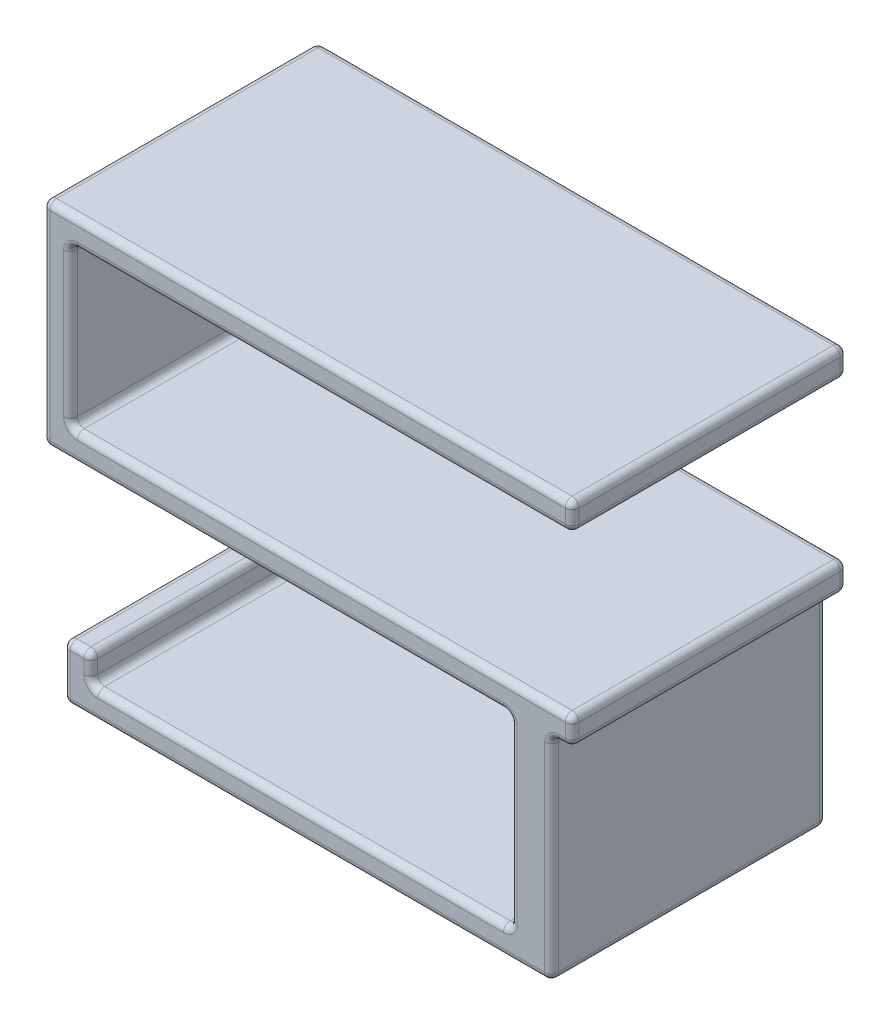
from build123d import *

# Parameters (mm, degrees)
ESBO_O2_W                 = 60
ESBO_O2_H                 = 3
RESSALTO_EXTRUS_O2_DEPTH  = 40
ESBO_O3_W                 = 16
ESBO_O3_H                 = 40
RESSALTO_EXTRUS_O3_DEPTH  = 3
ESBO_O4_W                 = 2
ESBO_O4_H                 = 40
RESSALTO_EXTRUS_O4_DEPTH  = 3
ESBO_O5_W                 = 2.000325399
ESBO_O5_H                 = 40
RESSALTO_EXTRUS_O5_DEPTH  = 26
ESBO_O6_W                 = 18
ESBO_O6_H                 = 3
RESSALTO_EXTRUS_O6_DEPTH  = 40
ESBO_O9_W                 = 3
ESBO_O9_H                 = 40
RESSALTO_EXTRUS_O8_DEPTH  = 3
ESBO_O10_W                = 40
ESBO_O10_H                = 3
RESSALTO_EXTRUS_O9_DEPTH  = 60
ESBO_O11_W                = 1
ESBO_O11_H                = 3
CORTE_EXTRUS_O1_DEPTH     = 40
ESBO_O12_W                = 2
ESBO_O12_H                = 3
CORTE_EXTRUS_O2_DEPTH     = 40
ESBO_O13_W                = 3
ESBO_O13_H                = 40
RESSALTO_EXTRUS_O10_DEPTH = 35
ESBO_O14_W                = 40
ESBO_O14_H                = 3
RESSALTO_EXTRUS_O11_DEPTH = 60
ESBO_O15_W                = 2
ESBO_O15_H                = 40
RESSALTO_EXTRUS_O12_DEPTH = 3
ESBO_O16_W                = 3
ESBO_O16_H                = 40
RESSALTO_EXTRUS_O13_DEPTH = 32
ESBO_O17_W                = 40
ESBO_O17_H                = 3
RESSALTO_EXTRUS_O14_DEPTH = 1
ESBO_O18_W                = 3
ESBO_O18_H                = 35
CORTE_EXTRUS_O3_DEPTH     = 40
ESBO_O19_W                = 1
ESBO_O19_H                = 3
RESSALTO_EXTRUS_O15_DEPTH = 40
ESBO_O20_W                = 1
ESBO_O20_H                = 3
RESSALTO_EXTRUS_O16_DEPTH = 40
ESBO_O21_W                = 1
ESBO_O21_H                = 29
RESSALTO_EXTRUS_O17_DEPTH = 40
ESBO_O22_W                = 57
ESBO_O22_H                = 3
RESSALTO_EXTRUS_O18_DEPTH = 40
ESBO_O23_W                = 60
ESBO_O23_H                = 3
CORTE_EXTRUS_O4_DEPTH     = 40
ESBO_O24_W                = 77
ESBO_O24_H                = 1
RESSALTO_EXTRUS_O19_DEPTH = 40
ESBO_O25_W                = 77
ESBO_O25_H                = 4
RESSALTO_EXTRUS_O20_DEPTH = 40
ESBO_O26_W                = 60
ESBO_O26_H                = 3
CORTE_EXTRUS_O5_DEPTH     = 40
ESBO_O27_W                = 1
ESBO_O27_H                = 23
RESSALTO_EXTRUS_O21_DEPTH = 40
ESBO_O28_W                = 3
ESBO_O28_H                = 31
RESSALTO_EXTRUS_O22_DEPTH = 40
ESBO_O29_W                = 54
ESBO_O29_H                = 1
RESSALTO_EXTRUS_O24_DEPTH = 40
ESBO_O33_W                = 4
ESBO_O33_H                = 8
RESSALTO_EXTRUS_O25_DEPTH = 40
ESBO_O35_W                = 4.03295804
ESBO_O35_H                = 4
CORTE_EXTRUS_O6_DEPTH     = 40
ESBO_O36_W                = 3
ESBO_O36_H                = 4
RESSALTO_EXTRUS_O26_DEPTH = 40
ESBO_O37_W                = 4
ESBO_O37_H                = 8
RESSALTO_EXTRUS_O27_DEPTH = 40
FILETE1_R                 = 1
FILETE2_R                 = 1


with BuildPart() as part:
    # Esboço2 → Ressalto-extrusão2 (new body)
    with BuildSketch(Plane.XY):
        with Locations((-18.473534946, 5.269414246)):
            Rectangle(ESBO_O2_W, ESBO_O2_H)
    extrude(amount=RESSALTO_EXTRUS_O2_DEPTH)

    # Esboço3 → Ressalto-extrusão3 (add)
    with BuildSketch(Plane(origin=(0, 6.769414246, 0), x_dir=(1, 0, 0), z_dir=(0, 1, 0))):
        with Locations((-54.473534946, -20)):
            Rectangle(ESBO_O3_W, ESBO_O3_H)
    extrude(amount=RESSALTO_EXTRUS_O3_DEPTH)

    # Esboço4 → Ressalto-extrusão4 (add)
    with BuildSketch(Plane.XZ.offset(-6.769414246)):
        with Locations((-63.473534946, 20)):
            Rectangle(ESBO_O4_W, ESBO_O4_H)
    extrude(amount=-RESSALTO_EXTRUS_O4_DEPTH)

    # Esboço5 → Ressalto-extrusão5 (add)
    with BuildSketch(Plane.XZ.offset(-6.769414246)):
        with Locations((-63.473372247, 20)):
            Rectangle(ESBO_O5_W, ESBO_O5_H)
    extrude(amount=RESSALTO_EXTRUS_O5_DEPTH)

    # Esboço6 → Ressalto-extrusão6 (add)
    with BuildSketch(Plane.XY.offset(40)):
        with Locations((-55.473534946, -17.730585754)):
            Rectangle(ESBO_O6_W, ESBO_O6_H)
    extrude(amount=-RESSALTO_EXTRUS_O6_DEPTH)

    # Esboço9 → Ressalto-extrusão8 (add)
    with BuildSketch(Plane(origin=(0, -16.230585754, 0), x_dir=(1, 0, 0), z_dir=(0, 1, 0))):
        with Locations((-47.973534946, -20)):
            Rectangle(ESBO_O9_W, ESBO_O9_H)
    extrude(amount=RESSALTO_EXTRUS_O8_DEPTH)

    # Esboço10 → Ressalto-extrusão9 (add)
    with BuildSketch(Plane(origin=(-46.473534946, 0, 0), x_dir=(0, 0, -1), z_dir=(1, 0, 0))):
        with Locations((-20, -14.730585754)):
            Rectangle(ESBO_O10_W, ESBO_O10_H)
    extrude(amount=RESSALTO_EXTRUS_O9_DEPTH)

    # Esboço11 → Corte-extrusão1 (cut)
    with BuildSketch(Plane.XY.offset(40)):
        with Locations((-48.973534946, -14.730585754)):
            Rectangle(ESBO_O11_W, ESBO_O11_H)
    extrude(amount=-CORTE_EXTRUS_O1_DEPTH, mode=Mode.SUBTRACT)

    # Esboço12 → Corte-extrusão2 (cut)
    with BuildSketch(Plane.XY.offset(40)):
        with Locations((12.526465054, -14.730585754)):
            Rectangle(ESBO_O12_W, ESBO_O12_H)
    extrude(amount=-CORTE_EXTRUS_O2_DEPTH, mode=Mode.SUBTRACT)

    # Esboço13 → Ressalto-extrusão10 (add)
    with BuildSketch(Plane.XZ.offset(16.230585754)):
        with Locations((7.026465054, 20)):
            Rectangle(ESBO_O13_W, ESBO_O13_H)
    extrude(amount=RESSALTO_EXTRUS_O10_DEPTH)

    # Esboço14 → Ressalto-extrusão11 (add)
    with BuildSketch(Plane.ZY.offset(-5.526465054)):
        with Locations((20, -49.730585754)):
            Rectangle(ESBO_O14_W, ESBO_O14_H)
    extrude(amount=RESSALTO_EXTRUS_O11_DEPTH)

    # Esboço15 → Ressalto-extrusão12 (add)
    with BuildSketch(Plane(origin=(0, -48.230585754, 0), x_dir=(1, 0, 0), z_dir=(0, 1, 0))):
        with Locations((-53.473534946, -20)):
            Rectangle(ESBO_O15_W, ESBO_O15_H)
    extrude(amount=RESSALTO_EXTRUS_O12_DEPTH)

    # Esboço16 → Ressalto-extrusão13 (add)
    with BuildSketch(Plane(origin=(0, -48.230585754, 0), x_dir=(1, 0, 0), z_dir=(0, 1, 0))):
        with Locations((4.026465054, -20)):
            Rectangle(ESBO_O16_W, ESBO_O16_H)
    extrude(amount=RESSALTO_EXTRUS_O13_DEPTH)

    # Esboço17 → Ressalto-extrusão14 (add)
    with BuildSketch(Plane(origin=(-46.473534946, 0, 0), x_dir=(0, 0, -1), z_dir=(1, 0, 0))):
        with Locations((-20, -17.730585754)):
            Rectangle(ESBO_O17_W, ESBO_O17_H)
    extrude(amount=RESSALTO_EXTRUS_O14_DEPTH)

    # Esboço18 → Corte-extrusão3 (cut)
    with BuildSketch(Plane.XY.offset(40)):
        with Locations((7.026465054, -33.730585754)):
            Rectangle(ESBO_O18_W, ESBO_O18_H)
    extrude(amount=-CORTE_EXTRUS_O3_DEPTH, mode=Mode.SUBTRACT)

    # Esboço19 → Ressalto-extrusão15 (add)
    with BuildSketch(Plane.XY.offset(40)):
        with Locations((-45.973534946, 8.269414246)):
            Rectangle(ESBO_O19_W, ESBO_O19_H)
    extrude(amount=-RESSALTO_EXTRUS_O15_DEPTH)

    # Esboço20 → Ressalto-extrusão16 (add)
    with BuildSketch(Plane.XY.offset(40)):
        with Locations((-51.973534946, -46.730585754)):
            Rectangle(ESBO_O20_W, ESBO_O20_H)
    extrude(amount=-RESSALTO_EXTRUS_O16_DEPTH)

    # Esboço21 → Ressalto-extrusão17 (add)
    with BuildSketch(Plane.XY.offset(40)):
        with Locations((-64.973534946, -4.730585754)):
            Rectangle(ESBO_O21_W, ESBO_O21_H)
    extrude(amount=-RESSALTO_EXTRUS_O17_DEPTH)

    # Esboço22 → Ressalto-extrusão18 (add)
    with BuildSketch(Plane.XY.offset(40)):
        with Locations((-16.973534946, -17.730585754)):
            Rectangle(ESBO_O22_W, ESBO_O22_H)
    extrude(amount=-RESSALTO_EXTRUS_O18_DEPTH)

    # Esboço23 → Corte-extrusão4 (cut)
    with BuildSketch(Plane.XY.offset(40)):
        with Locations((-18.473534946, -14.730585754)):
            Rectangle(ESBO_O23_W, ESBO_O23_H)
    extrude(amount=-CORTE_EXTRUS_O4_DEPTH, mode=Mode.SUBTRACT)

    # Esboço24 → Ressalto-extrusão19 (add)
    with BuildSketch(Plane.XY.offset(40)):
        with Locations((-26.973534946, -19.730585754)):
            Rectangle(ESBO_O24_W, ESBO_O24_H)
    extrude(amount=-RESSALTO_EXTRUS_O19_DEPTH)

    # Esboço25 → Ressalto-extrusão20 (add)
    with BuildSketch(Plane.XY.offset(40)):
        with Locations((-26.973534946, 8.769414246)):
            Rectangle(ESBO_O25_W, ESBO_O25_H)
    extrude(amount=-RESSALTO_EXTRUS_O20_DEPTH)

    # Esboço26 → Corte-extrusão5 (cut)
    with BuildSketch(Plane.XY.offset(40)):
        with Locations((-18.473534946, 5.269414246)):
            Rectangle(ESBO_O26_W, ESBO_O26_H)
    extrude(amount=-CORTE_EXTRUS_O5_DEPTH, mode=Mode.SUBTRACT)

    # Esboço27 → Ressalto-extrusão21 (add)
    with BuildSketch(Plane.XY.offset(40)):
        with Locations((-61.973209547, -4.730585754)):
            Rectangle(ESBO_O27_W, ESBO_O27_H)
    extrude(amount=-RESSALTO_EXTRUS_O21_DEPTH)

    # Esboço28 → Ressalto-extrusão22 (add)
    with BuildSketch(Plane.XY.offset(40)):
        with Locations((7.026465054, -35.730585754)):
            Rectangle(ESBO_O28_W, ESBO_O28_H)
    extrude(amount=-RESSALTO_EXTRUS_O22_DEPTH)

    # Esboço29 → Ressalto-extrusão24 (add)
    with BuildSketch(Plane.XY.offset(40)):
        with Locations((-24.473534946, -47.730585754)):
            Rectangle(ESBO_O29_W, ESBO_O29_H)
    extrude(amount=-RESSALTO_EXTRUS_O24_DEPTH)

    # Esboço33 → Ressalto-extrusão25 (add)
    with BuildSketch(Plane.XY.offset(40)):
        with Locations((-53.506492986, -47.230585754)):
            Rectangle(ESBO_O33_W, ESBO_O33_H)
    extrude(amount=-RESSALTO_EXTRUS_O25_DEPTH)

    # Esboço35 → Corte-extrusão6 (cut)
    with BuildSketch(Plane.XY.offset(40)):
        with Locations((-53.490013966, -45.230585754)):
            Rectangle(ESBO_O35_W, ESBO_O35_H)
    extrude(amount=-CORTE_EXTRUS_O6_DEPTH, mode=Mode.SUBTRACT)

    # Esboço36 → Ressalto-extrusão26 (add)
    with BuildSketch(Plane.XY.offset(40)):
        with Locations((-57.006492986, -49.230585754)):
            Rectangle(ESBO_O36_W, ESBO_O36_H)
    extrude(amount=-RESSALTO_EXTRUS_O26_DEPTH)

    # Esboço37 → Ressalto-extrusão27 (add)
    with BuildSketch(Plane.XY.offset(40)):
        with Locations((-60.506492986, -47.230585754)):
            Rectangle(ESBO_O37_W, ESBO_O37_H)
    extrude(amount=-RESSALTO_EXTRUS_O27_DEPTH)

    # Filete1
    filete1_edges = [part.edges().sort_by_distance(p)[0] for p in [
        (11.526465054, -16.230585754, 20),
        (11.526465054, -20.230585754, 20),
        (2.526465054, -20.230585754, 20),
        (-65.473534946, -20.230585754, 20),
        (11.526465054, 10.769414246, 20),
        (-65.473534946, 10.769414246, 20),
        (11.526465054, 6.769414246, 20),
        (-61.473209547, 6.769414246, 20),
        (-61.473209547, -16.230585754, 20),
        (8.526465054, -20.230585754, 20),
        (8.526465054, -51.230585754, 20),
        (2.526465054, -47.230585754, 20),
        (-58.506492986, -47.230585754, 20),
        (-58.506492986, -43.230585754, 20),
        (-62.506492986, -51.230585754, 20),
        (-62.506492986, -43.230585754, 20),
    ]]
    fillet(filete1_edges, radius=FILETE1_R)

    # Filete2
    filete2_edges = [part.edges().sort_by_distance(p)[0] for p in [
        (-26.973534946, 10.769414246, 0),
        (-26.973534946, 10.769414246, 40),
        (-27.990013966, -47.230585754, 40),
        (-58.506492986, -45.230585754, 40),
        (-60.506492986, -43.230585754, 40),
        (-62.506492986, -47.230585754, 40),
        (-26.990013966, -51.230585754, 40),
        (8.526465054, -35.730585754, 40),
        (10.026465054, -20.230585754, 40),
        (11.526465054, -18.230585754, 40),
        (-24.973372247, -16.230585754, 40),
        (-61.473209547, -4.730585754, 40),
        (-24.973372247, 6.769414246, 40),
        (11.526465054, 8.769414246, 40),
        (-65.473534946, -4.730585754, 40),
        (-31.473534946, -20.230585754, 40),
        (2.526465054, -33.730585754, 40),
        (11.233571835, 7.062307465, 40),
        (11.233571835, 10.476521027, 40),
        (11.233571835, -16.523478973, 40),
        (11.233571835, -19.937692535, 40),
        (8.233571835, -50.937692535, 40),
        (-62.213599768, -43.523478973, 40),
        (-62.213599768, -50.937692535, 40),
        (-58.799386205, -43.523478973, 40),
        (-65.180641727, -19.937692535, 40),
        (-65.180641727, 10.476521027, 40),
        (-65.473534946, -4.730585754, 0),
        (-26.990013966, -51.230585754, 0),
        (-62.506492986, -47.230585754, 0),
        (-60.506492986, -43.230585754, 0),
        (-58.506492986, -45.230585754, 0),
        (-27.990013966, -47.230585754, 0),
        (2.526465054, -33.730585754, 0),
        (-31.473534946, -20.230585754, 0),
        (11.526465054, 8.769414246, 0),
        (-24.973372247, 6.769414246, 0),
        (-61.473209547, -4.730585754, 0),
        (-24.973372247, -16.230585754, 0),
        (11.526465054, -18.230585754, 0),
        (10.026465054, -20.230585754, 0),
        (8.526465054, -35.730585754, 0),
        (11.233571835, 7.062307465, 0),
        (11.233571835, 10.476521027, 0),
        (11.233571835, -16.523478973, 0),
        (11.233571835, -19.937692535, 0),
        (8.233571835, -50.937692535, 0),
        (-62.213599768, -43.523478973, 0),
        (-62.213599768, -50.937692535, 0),
        (-58.799386205, -43.523478973, 0),
        (-65.180641727, -19.937692535, 0),
        (-65.180641727, 10.476521027, 0),
        (-61.180316328, 6.476521027, 40),
        (-61.180316328, 6.476521027, 0),
        (-61.180316328, -15.937692535, 40),
        (-61.180316328, -15.937692535, 0),
        (2.233571835, -20.523478973, 0),
        (2.233571835, -20.523478973, 40),
        (2.233571835, -46.937692535, 40),
        (2.233571835, -46.937692535, 0),
        (-58.213599768, -46.937692535, 40),
        (-58.213599768, -46.937692535, 0),
        (8.819358273, -20.523478973, 40),
        (8.819358273, -20.523478973, 0),
    ]]
    fillet(filete2_edges, radius=FILETE2_R)


solid = part.part
